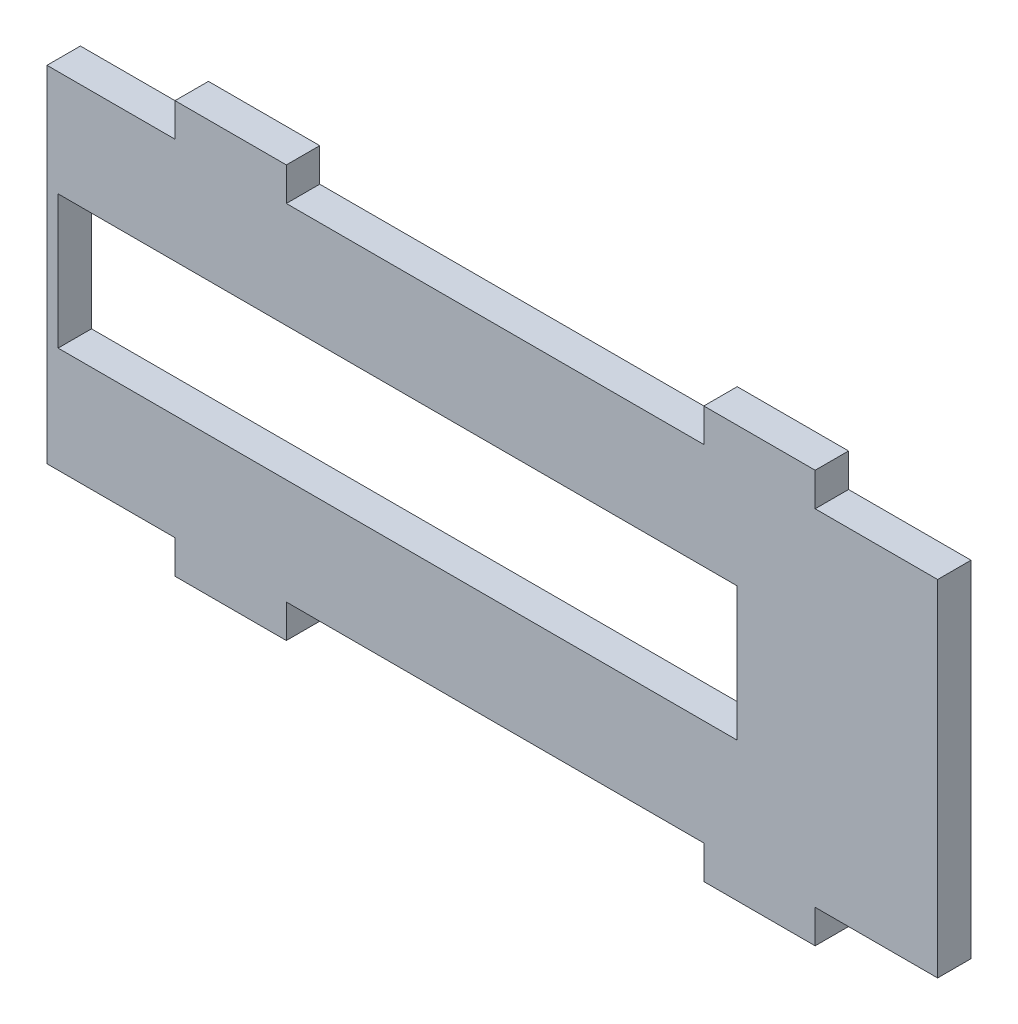
from build123d import *

# Parameters (mm, degrees)
SKETCH_1_W      = 80
SKETCH_1_H      = 31
SKETCH_1_W_2    = 61
SKETCH_1_H_2    = 12
EXTRUDE_1_DEPTH = 3
SKETCH_2_W      = 10
SKETCH_2_H      = 3
EXTRUDE_2_DEPTH = 3


with BuildPart() as part:
    # 草图1 → 凸台-拉伸1 (new body)
    with BuildSketch(Plane.XY):
        with Locations((40, 15.5)):
            Rectangle(SKETCH_1_W, SKETCH_1_H)
        with Locations((31.5, 15.5)):
            Rectangle(SKETCH_1_W_2, SKETCH_1_H_2, mode=Mode.SUBTRACT)
    extrude(amount=EXTRUDE_1_DEPTH)

    # 草图2 → 凸台-拉伸2 (add)
    with BuildSketch(Plane.XY.offset(3)):
        with Locations((16.5, 32.5)):
            Rectangle(SKETCH_2_W, SKETCH_2_H)
        with Locations((64, 32.5)):
            Rectangle(SKETCH_2_W, SKETCH_2_H)
        with Locations((64, -1.5)):
            Rectangle(SKETCH_2_W, SKETCH_2_H)
        with Locations((16.5, -1.5)):
            Rectangle(SKETCH_2_W, SKETCH_2_H)
    extrude(amount=-EXTRUDE_2_DEPTH)


solid = part.part
